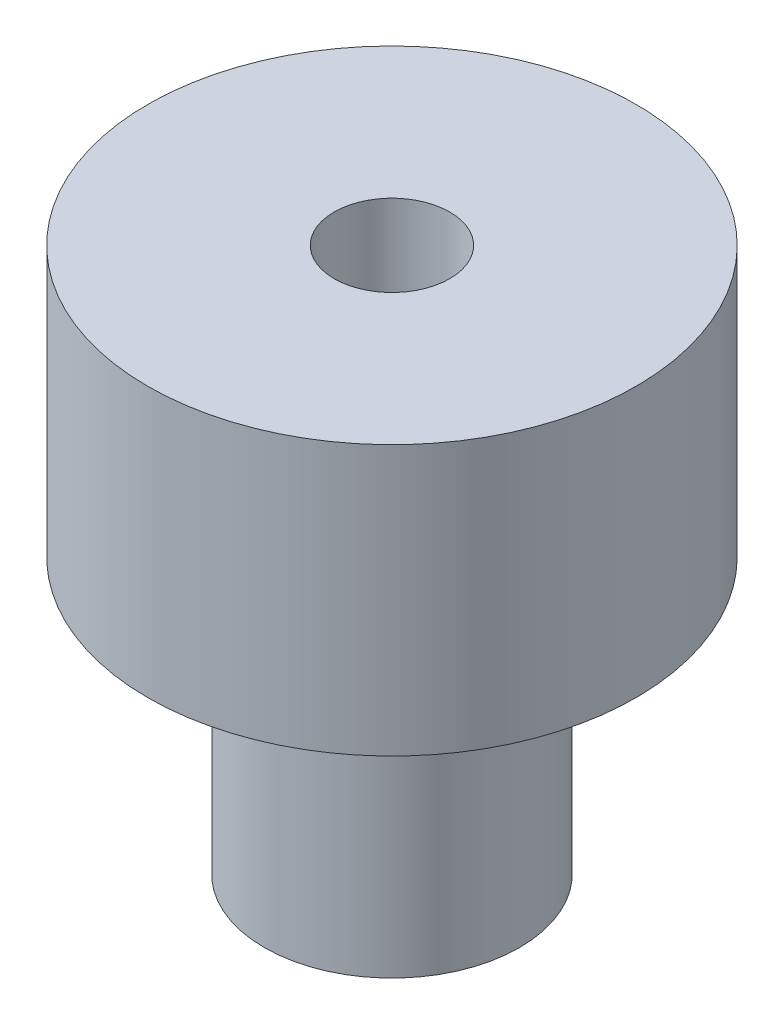
from build123d import *

# Parameters (mm, degrees)
SKETCH1_R           = 6.7
SKETCH1_R_2         = 1.586
BOSS_EXTRUDE1_DEPTH = 7.4
SKETCH2_R           = 3.5
SKETCH2_R_2         = 1.586
BOSS_EXTRUDE2_DEPTH = 7.54
SKETCH3_R           = 1.25
CUT_EXTRUDE1_DEPTH  = 10


with BuildPart() as part:
    # Sketch1 → Boss-Extrude1 (new body)
    with BuildSketch(Plane(origin=(0, 0, 0), x_dir=(1, 0, 0), z_dir=(0, 1, 0))):
        Circle(SKETCH1_R)
        Circle(SKETCH1_R_2, mode=Mode.SUBTRACT)
    extrude(amount=BOSS_EXTRUDE1_DEPTH)

    # Sketch2 → Boss-Extrude2 (add)
    with BuildSketch(Plane.XZ):
        Circle(SKETCH2_R)
        Circle(SKETCH2_R_2, mode=Mode.SUBTRACT)
    extrude(amount=BOSS_EXTRUDE2_DEPTH)

    # Sketch3 → Cut-Extrude1 (cut)
    with BuildSketch(Plane(origin=(0, 0, 0), x_dir=(0, 0, -1), z_dir=(1, 0, 0))):
        with Locations((0, -3.77)):
            Circle(SKETCH3_R)
    extrude(amount=-CUT_EXTRUDE1_DEPTH, mode=Mode.SUBTRACT)


solid = part.part
